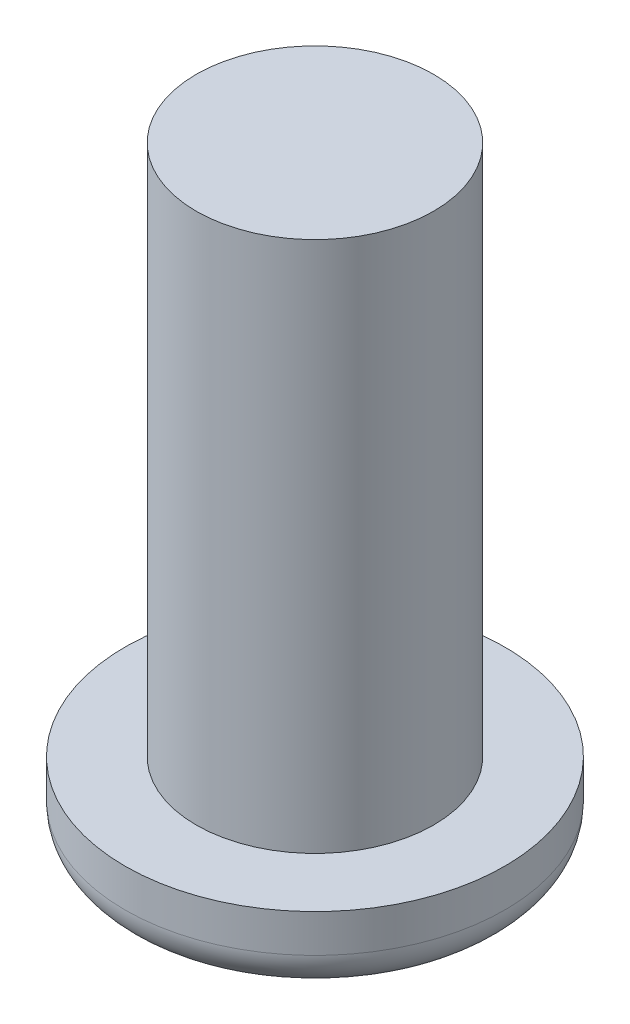
from build123d import *

# Parameters (mm, degrees)
SKETCH1_R           = 6.35
BOSS_EXTRUDE1_DEPTH = 2.54
FILLET2_R           = 1.27
SKETCH2_R           = 3.96875
BOSS_EXTRUDE3_DEPTH = 17.78


with BuildPart() as part:
    # Sketch1 → Boss-Extrude1 (new body)
    with BuildSketch(Plane(origin=(0, 0, 0), x_dir=(1, 0, 0), z_dir=(0, 1, 0))):
        Circle(SKETCH1_R)
    extrude(amount=BOSS_EXTRUDE1_DEPTH)

    # Fillet2
    fillet2_edges = [part.edges().sort_by_distance(p)[0] for p in [
        (-6.35, 0, 0),
    ]]
    fillet(fillet2_edges, radius=FILLET2_R)

    # Sketch2 → Boss-Extrude3 (add)
    with BuildSketch(Plane(origin=(0, 2.54, 0), x_dir=(1, 0, 0), z_dir=(0, 1, 0))):
        Circle(SKETCH2_R)
    extrude(amount=BOSS_EXTRUDE3_DEPTH)


solid = part.part
